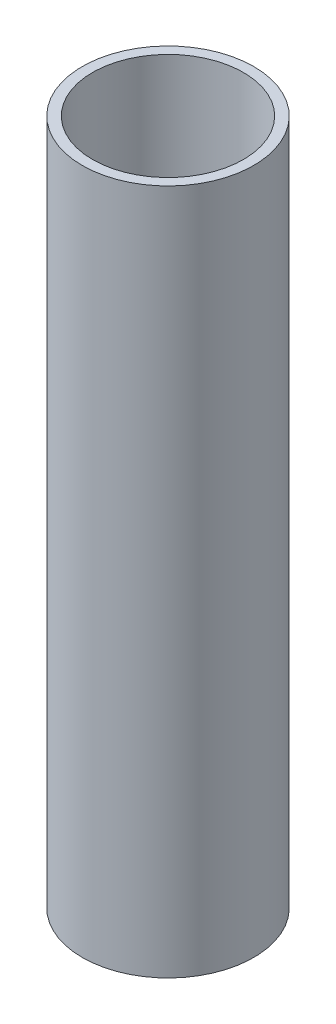
from build123d import *

# Parameters (mm, degrees)
SKETCH1_R           = 12.7
SKETCH1_R_2         = 11.176
BOSS_EXTRUDE1_DEPTH = 101.6


with BuildPart() as part:
    # Sketch1 → Boss-Extrude1 (new body)
    with BuildSketch(Plane(origin=(0, 0, 0), x_dir=(1, 0, 0), z_dir=(0, 1, 0))):
        Circle(SKETCH1_R)
        Circle(SKETCH1_R_2, mode=Mode.SUBTRACT)
    extrude(amount=BOSS_EXTRUDE1_DEPTH)


solid = part.part
